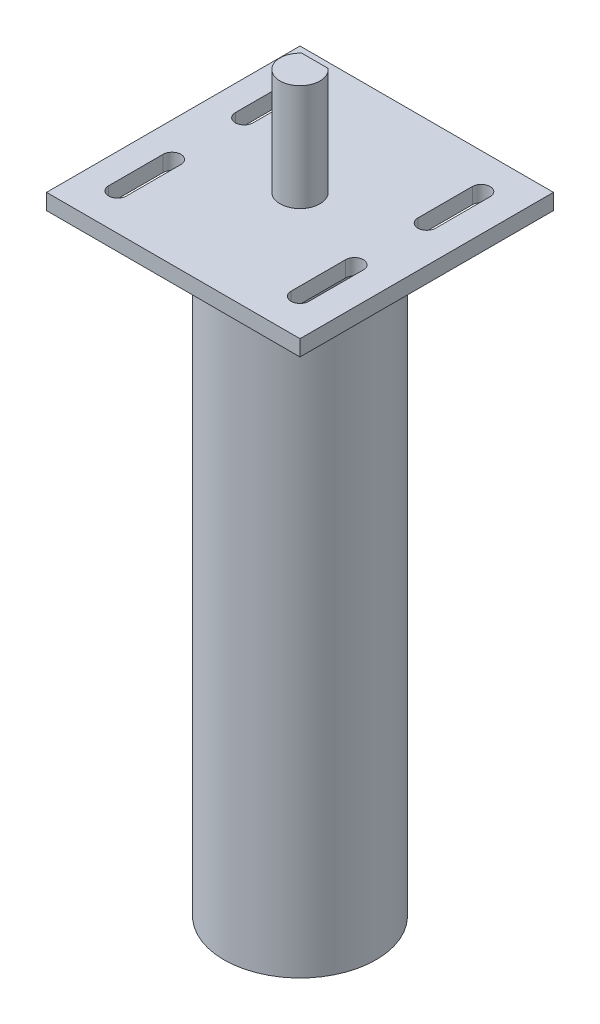
from build123d import *

# Parameters (mm, degrees)
SKETCH1_R           = 15.24
BOSS_EXTRUDE1_DEPTH = 122.428
SKETCH2_W           = 50.8
SKETCH2_H           = 50.8
BOSS_EXTRUDE2_DEPTH = 3.175
SKETCH3_R           = 4
BOSS_EXTRUDE3_DEPTH = 21.336
CUT_EXTRUDE1_DEPTH  = 21.336
CUT_EXTRUDE2_DEPTH  = 3.175


with BuildPart() as part:
    # Sketch1 → Boss-Extrude1 (new body)
    with BuildSketch(Plane(origin=(0, 0, 0), x_dir=(1, 0, 0), z_dir=(0, 1, 0))):
        Circle(SKETCH1_R)
    extrude(amount=BOSS_EXTRUDE1_DEPTH)

    # Sketch2 → Boss-Extrude2 (add)
    with BuildSketch(Plane(origin=(0, 122.428, 0), x_dir=(1, 0, 0), z_dir=(0, 1, 0))):
        Rectangle(SKETCH2_W, SKETCH2_H)
    extrude(amount=BOSS_EXTRUDE2_DEPTH)

    # Sketch3 → Boss-Extrude3 (add)
    with BuildSketch(Plane(origin=(0, 125.603, 0), x_dir=(1, 0, 0), z_dir=(0, 1, 0))):
        Circle(SKETCH3_R)
    extrude(amount=BOSS_EXTRUDE3_DEPTH)

    # Sketch4 → Cut-Extrude1 (cut)
    with BuildSketch(Plane(origin=(0, 146.939, 0), x_dir=(1, 0, 0), z_dir=(0, 1, 0))):
        with BuildLine():
            Line((2.645751311, 3), (-2.645751311, 3))
            ThreePointArc((-2.645751311, 3), (0, 4), (2.645751311, 3))
        make_face()
    extrude(amount=-CUT_EXTRUDE1_DEPTH, mode=Mode.SUBTRACT)

    # Sketch5 → Cut-Extrude2 (cut)
    with BuildSketch(Plane(origin=(0, 125.603, 0), x_dir=(1, 0, 0), z_dir=(0, 1, 0))):
        with BuildLine():
            Line((-16.764, 18.288), (-16.764, 7.366))
            ThreePointArc((-16.764, 7.366), (-18.542, 5.588), (-20.32, 7.366))
            Line((-20.32, 7.366), (-20.32, 18.288))
            ThreePointArc((-20.32, 18.288), (-18.542, 20.066), (-16.764, 18.288))
        make_face()
        with BuildLine():
            Line((-16.764, -7.112), (-16.764, -18.034))
            ThreePointArc((-16.764, -18.034), (-18.542, -19.812), (-20.32, -18.034))
            Line((-20.32, -18.034), (-20.32, -7.112))
            ThreePointArc((-20.32, -7.112), (-18.542, -5.334), (-16.764, -7.112))
        make_face()
        with BuildLine():
            Line((19.812, -7.112), (19.812, -18.034))
            ThreePointArc((19.812, -18.034), (18.034, -19.812), (16.256, -18.034))
            Line((16.256, -18.034), (16.256, -7.112))
            ThreePointArc((16.256, -7.112), (18.034, -5.334), (19.812, -7.112))
        make_face()
        with BuildLine():
            Line((19.812, 18.288), (19.812, 7.366))
            ThreePointArc((19.812, 7.366), (18.034, 5.588), (16.256, 7.366))
            Line((16.256, 7.366), (16.256, 18.288))
            ThreePointArc((16.256, 18.288), (18.034, 20.066), (19.812, 18.288))
        make_face()
    extrude(amount=-CUT_EXTRUDE2_DEPTH, mode=Mode.SUBTRACT)


solid = part.part
